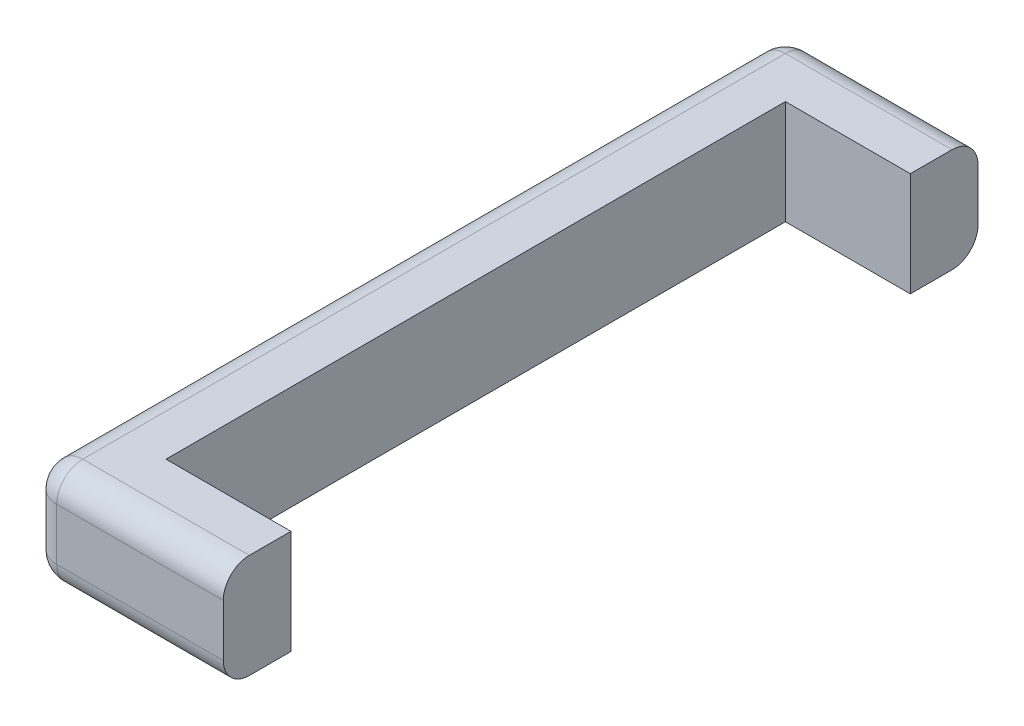
from build123d import *

# Parameters (mm, degrees)
BOSS_EXTRUDE1_DEPTH = 63.5
FILLET1_R           = 31.75


with BuildPart() as part:
    # Sketch1 → Boss-Extrude1 (new body, symmetric)
    with BuildSketch(Plane(origin=(0, 0, 0), x_dir=(1, 0, 0), z_dir=(0, 1, 0))):
        with BuildLine():
            Line((0, 377.825), (0, -377.825))
            Line((0, -377.825), (152.4, -377.825))
            Line((152.4, -377.825), (152.4, -460.375))
            Line((152.4, -460.375), (-50.8, -460.375))
            ThreePointArc((-50.8, -460.375), (-73.250640303, -451.075640303), (-82.55, -428.625))
            Line((-82.55, -428.625), (-82.55, 428.625))
            ThreePointArc((-82.55, 428.625), (-73.250640303, 451.075640303), (-50.8, 460.375))
            Line((-50.8, 460.375), (152.4, 460.375))
            Line((152.4, 460.375), (152.4, 377.825))
            Line((152.4, 377.825), (0, 377.825))
        make_face()
    extrude(amount=BOSS_EXTRUDE1_DEPTH, both=True)

    # Fillet1
    fillet1_edges = [part.edges().sort_by_distance(p)[0] for p in [
        (-73.250640303, -63.5, 451.075640303),
        (-82.55, -63.5, 0),
        (-73.250640303, -63.5, -451.075640303),
        (50.8, -63.5, -460.375),
        (50.8, 63.5, -460.375),
        (-73.250640303, 63.5, -451.075640303),
        (-82.55, 63.5, 0),
        (-73.250640303, 63.5, 451.075640303),
        (50.8, 63.5, 460.375),
        (50.8, -63.5, 460.375),
    ]]
    fillet(fillet1_edges, radius=FILLET1_R)


solid = part.part
